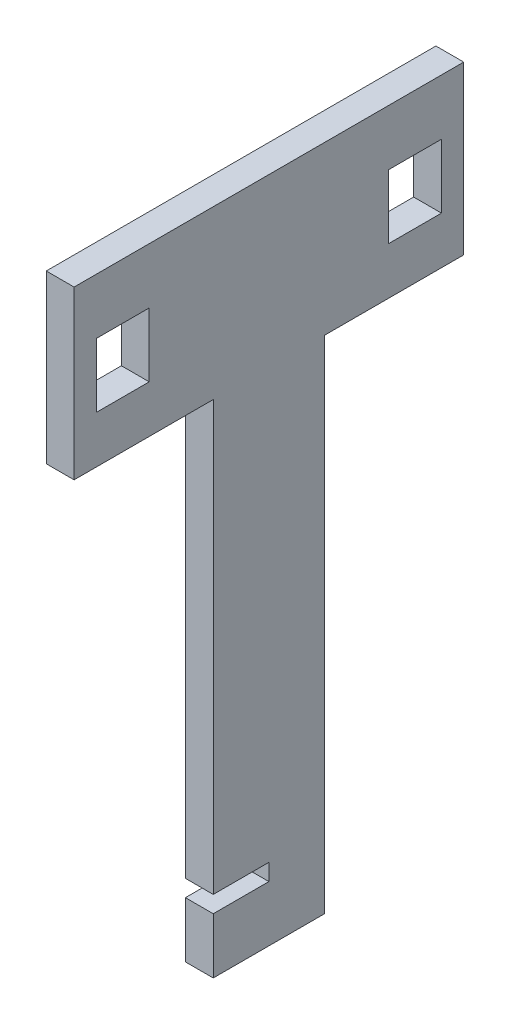
from build123d import *

# Parameters (mm, degrees)
SKETCH1_W           = 5
SKETCH1_H           = 120
BOSS_EXTRUDE1_DEPTH = 70
SKETCH2_W           = 35
SKETCH2_H           = 3
CUT_EXTRUDE1_DEPTH  = 6
SKETCH3_W           = 9.5
SKETCH3_H           = 11.5
CUT_EXTRUDE2_DEPTH  = 6
SKETCH5_W           = 25
SKETCH5_H           = 90
CUT_EXTRUDE3_DEPTH  = 10


with BuildPart() as part:
    # Sketch1 → Boss-Extrude1 (new body)
    with BuildSketch(Plane.XY):
        with Locations((2.5, 60)):
            Rectangle(SKETCH1_W, SKETCH1_H)
    extrude(amount=BOSS_EXTRUDE1_DEPTH)

    # Sketch2 → Cut-Extrude1 (cut, through all)
    with BuildSketch(Plane(origin=(5, 0, 0), x_dir=(0, 0, -1), z_dir=(1, 0, 0))):
        with Locations((-52.5, 11.5)):
            Rectangle(SKETCH2_W, SKETCH2_H)
    extrude(amount=-CUT_EXTRUDE1_DEPTH, mode=Mode.SUBTRACT)

    # Sketch3 → Cut-Extrude2 (cut, through all)
    with BuildSketch(Plane(origin=(0, 0, 0), x_dir=(0, 0, -1), z_dir=(1, 0, 0))):
        with Locations((-8.75, 104.25)):
            Rectangle(SKETCH3_W, SKETCH3_H)
        with Locations((-61.25, 104.25)):
            Rectangle(SKETCH3_W, SKETCH3_H)
    extrude(amount=CUT_EXTRUDE2_DEPTH, mode=Mode.SUBTRACT)

    # Sketch5 → Cut-Extrude3 (cut)
    with BuildSketch(Plane(origin=(5, 0, 0), x_dir=(0, 0, -1), z_dir=(1, 0, 0))):
        with Locations((-57.5, 45)):
            Rectangle(SKETCH5_W, SKETCH5_H)
        with Locations((-12.5, 45)):
            Rectangle(SKETCH5_W, SKETCH5_H)
    extrude(amount=-CUT_EXTRUDE3_DEPTH, mode=Mode.SUBTRACT)


solid = part.part
